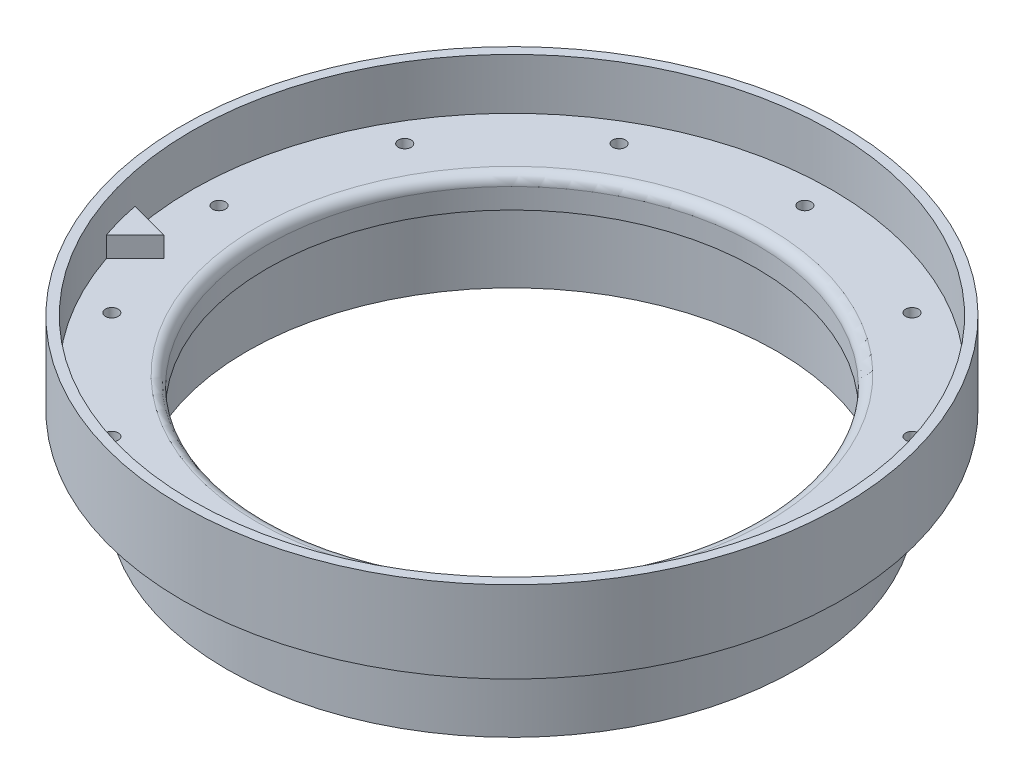
from build123d import *

# Parameters (mm, degrees)
F_3_48_TAPPED_HOLE1_D = 1.9939
CIRPATTERN1_COUNT     = 12
BOSS_EXTRUDE1_DEPTH   = 3.175


with BuildPart() as part:
    # Cross Section → Main (revolve)
    with BuildSketch(Plane.XY):
        with BuildLine():
            Line((-38.1, 0), (-38.1, -3.175))
            Line((-38.1, -3.175), (-41.2242, -3.175))
            Line((-41.2242, -3.175), (-41.2242, -15.875))
            Line((-41.2242, -15.875), (-44.3992, -15.875))
            Line((-44.3992, -15.875), (-44.3992, -3.175))
            Line((-44.3992, -3.175), (-51.2572, -3.175))
            Line((-51.2572, -3.175), (-51.2572, 9.525))
            Line((-51.2572, 9.525), (-49.784, 9.525))
            Line((-49.784, 9.525), (-49.784, 1.5875))
            Line((-49.784, 1.5875), (-39.6875, 1.5875))
            ThreePointArc((-39.6875, 1.5875), (-38.564967985, 1.122532015), (-38.1, 0))
        make_face()
    revolve(axis=Axis((0, 55, 0), (0, -1, 0)))

    # #3-48 Tapped Hole1 (through all)
    with Locations(Plane(origin=(0, 1.5875, 0), x_dir=(1, 0, 0), z_dir=(0, 1, 0))):
        with Locations((-45.5549, 0)):
            f_3_48_tapped_hole1 = Hole(F_3_48_TAPPED_HOLE1_D / 2)

    # CirPattern1: #3-48 Tapped Hole1 ×12 about axis
    cirpattern1_axis = Axis((0, 0, 0), (0, 1, 0))
    for i in range(1, CIRPATTERN1_COUNT):
        add(f_3_48_tapped_hole1.rotate(cirpattern1_axis, i * 360 / CIRPATTERN1_COUNT), mode=Mode.SUBTRACT)

    # Sketch3 → Boss-Extrude1 (add)
    with BuildSketch(Plane(origin=(0, 1.5875, 0), x_dir=(1, 0, 0), z_dir=(0, 1, 0))):
        with BuildLine():
            Line((-47.168007396, -15.925631363), (-42.677879335, -11.435503303))
            Line((-42.677879335, -11.435503303), (-48.811508332, -9.792002366))
            ThreePointArc((-48.811508332, -9.792002366), (-48.087651336, -12.885047341), (-47.168007396, -15.925631363))
        make_face()
    extrude(amount=BOSS_EXTRUDE1_DEPTH)


solid = part.part
